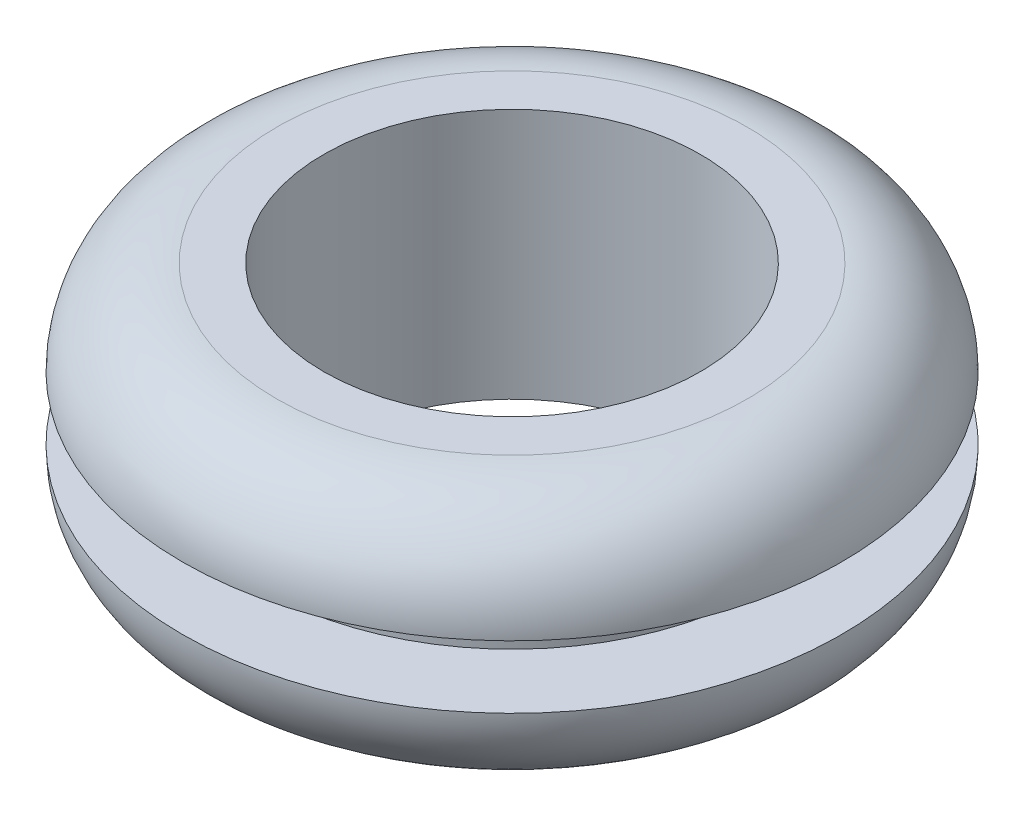
from build123d import *


with BuildPart() as part:
    # Sketch2 → Revolve1 (revolve)
    with BuildSketch(Plane.XY):
        with BuildLine():
            Line((6.35, 0.79375), (8.334375, 0.79375))
            ThreePointArc((8.334375, 0.79375), (7.636923023, 2.477548023), (5.953125, 3.175))
            Line((5.953125, 3.175), (4.7625, 3.175))
            Line((4.7625, 3.175), (4.7625, -3.175))
            Line((4.7625, -3.175), (5.953125, -3.175))
            ThreePointArc((5.953125, -3.175), (7.636923023, -2.477548023), (8.334375, -0.79375))
            Line((8.334375, -0.79375), (6.35, -0.79375))
            Line((6.35, -0.79375), (6.35, 0.79375))
        make_face()
    revolve(axis=Axis((0, 3.175, 0), (0, -1, 0)))


solid = part.part
